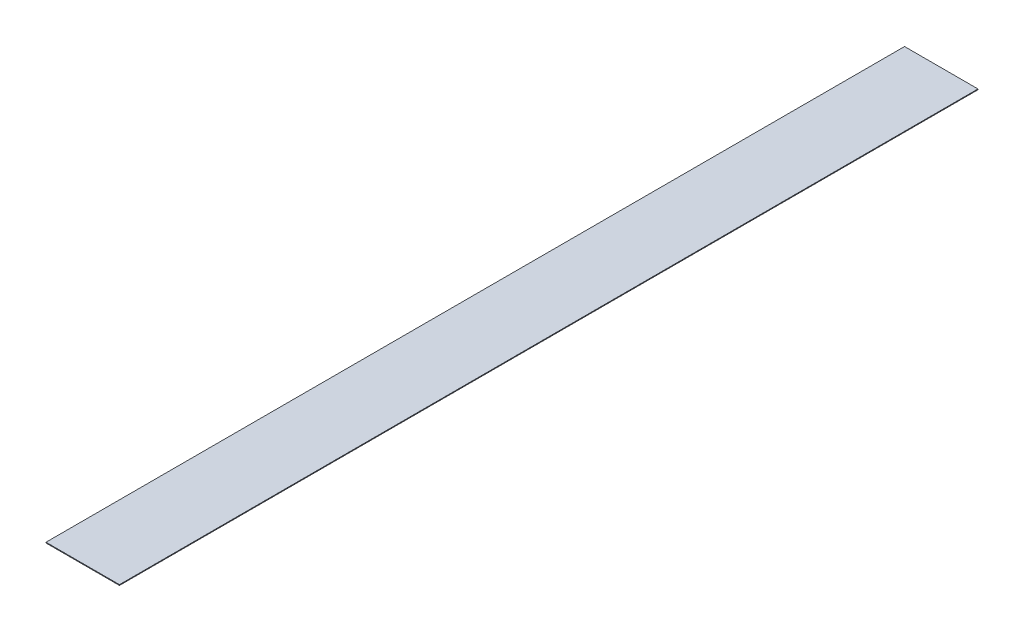
from build123d import *

# Parameters (mm, degrees)
SKETCH1_W           = 50.8
SKETCH1_H           = 593.725
BOSS_EXTRUDE1_DEPTH = 0.508


with BuildPart() as part:
    # Sketch1 → Boss-Extrude1 (new body)
    with BuildSketch(Plane(origin=(0, 0, 0), x_dir=(1, 0, 0), z_dir=(0, 1, 0))):
        with Locations((0, 296.8625)):
            Rectangle(SKETCH1_W, SKETCH1_H)
    extrude(amount=BOSS_EXTRUDE1_DEPTH)


solid = part.part
